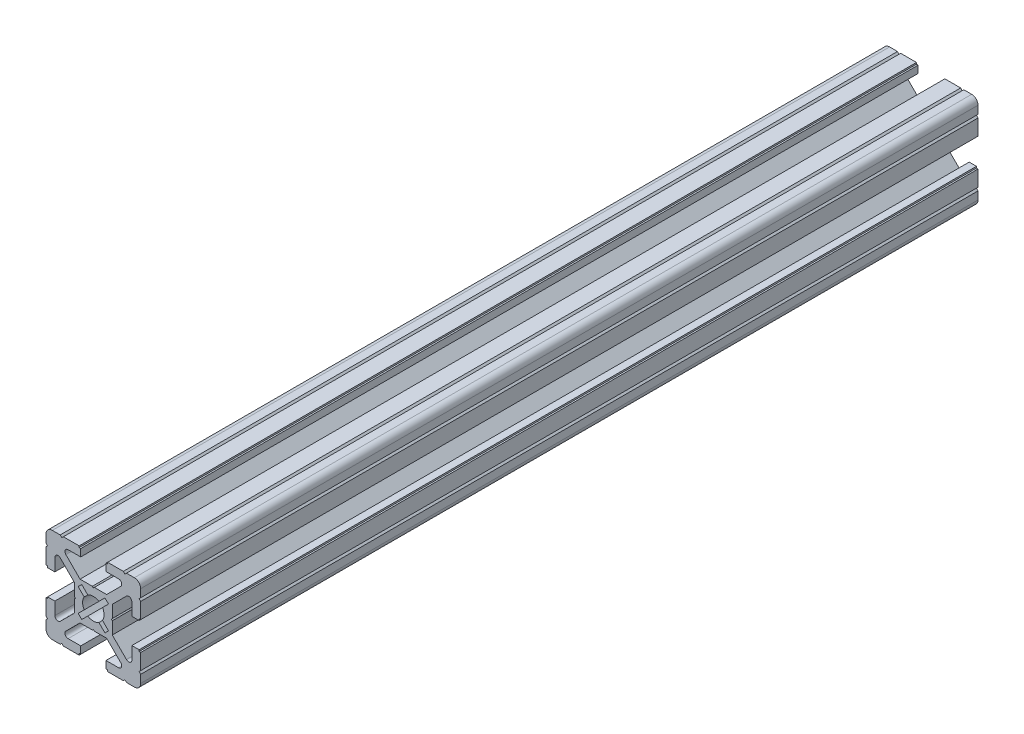
from build123d import *

# Parameters (mm, degrees)
BOSS_EXTRUDE1_DEPTH = 165
BOSS_EXTRUDE2_DEPTH = 100.28


with BuildPart() as part:
    # Sketch1 → Boss-Extrude1 (new body)
    with BuildSketch(Plane(origin=(0, 0, -65), x_dir=(-1, 0, 0), z_dir=(0, 0, -1))):
        with BuildLine():
            Line((-14.999999999, 12.999999999), (-14.999999999, 10.499999999))
            Line((-14.999999999, 10.499999999), (-14.499999999, 9.999999999))
            Line((-14.499999999, 9.999999999), (-14.999999999, 9.5))
            Line((-14.999999999, 9.5), (-14.999999999, 4.5))
            Line((-14.999999999, 4.5), (-14.5, 4.5))
            Line((-14.5, 4.5), (-14.5, 4))
            Line((-14.5, 4), (-12.200000005, 4))
            Line((-12.200000005, 4), (-12.200000005, 7.999999995))
            ThreePointArc((-12.200000005, 7.999999995), (-11.582683434, 8.923879532), (-10.492893215, 8.70710678))
            Line((-10.492893215, 8.70710678), (-6, 4.214213564))
            Line((-6, 4.214213564), (-6, 0.312520903))
            Line((-6, 0.312520903), (-5.7, 0))
            Line((-5.7, 0), (-6, -0.312520901))
            Line((-6, -0.312520901), (-6, -4.214213564))
            Line((-6, -4.214213564), (-10.492893215, -8.70710678))
            ThreePointArc((-10.492893215, -8.70710678), (-11.582683434, -8.923879532), (-12.200000005, -7.999999995))
            Line((-12.200000005, -7.999999995), (-12.200000005, -4))
            Line((-12.200000005, -4), (-14.5, -4))
            Line((-14.5, -4), (-14.5, -4.5))
            Line((-14.5, -4.5), (-14.999999999, -4.5))
            Line((-14.999999999, -4.5), (-14.999999999, -9.500000003))
            Line((-14.999999999, -9.500000003), (-14.499999999, -10.000000002))
            Line((-14.499999999, -10.000000002), (-14.999999999, -10.500000001))
            Line((-14.999999999, -10.500000001), (-14.999999999, -13))
            ThreePointArc((-14.999999999, -13), (-14.414213561, -14.414213562), (-12.999999999, -15))
            Line((-12.999999999, -15), (-10.5, -15))
            Line((-10.5, -15), (-10.000000001, -14.500000001))
            Line((-10.000000001, -14.500000001), (-9.500000001, -15))
            Line((-9.500000001, -15), (-4.5, -15))
            Line((-4.5, -15), (-4.5, -14.5))
            Line((-4.5, -14.5), (-4, -14.5))
            Line((-4, -14.5), (-4, -12.200000005))
            Line((-4, -12.200000005), (-7.999999995, -12.200000005))
            ThreePointArc((-7.999999995, -12.200000005), (-8.923879532, -11.582683434), (-8.70710678, -10.492893215))
            Line((-8.70710678, -10.492893215), (-4.214213564, -6))
            Line((-4.214213564, -6), (-0.312520903, -6))
            Line((-0.312520903, -6), (0, -5.7))
            Line((0, -5.7), (0.312520901, -6))
            Line((0.312520901, -6), (4.214213564, -6))
            Line((4.214213564, -6), (8.70710678, -10.492893215))
            ThreePointArc((8.70710678, -10.492893215), (8.923879532, -11.582683434), (7.999999995, -12.200000005))
            Line((7.999999995, -12.200000005), (4, -12.200000005))
            Line((4, -12.200000005), (4, -14.5))
            Line((4, -14.5), (4.5, -14.5))
            Line((4.5, -14.5), (4.5, -15))
            Line((4.5, -15), (9.500000001, -15))
            Line((9.500000001, -15), (9.989897949, -14.5))
            Line((9.989897949, -14.5), (10.489897949, -15))
            Line((10.489897949, -15), (13, -15))
            ThreePointArc((13, -15), (14.414213562, -14.414213562), (15, -13))
            Line((15, -13), (15, -10.5))
            Line((15, -10.5), (14.500000001, -10.000000001))
            Line((14.500000001, -10.000000001), (15, -9.500000001))
            Line((15, -9.500000001), (15, -4.5))
            Line((15, -4.5), (14.5, -4.5))
            Line((14.5, -4.5), (14.5, -4))
            Line((14.5, -4), (12.200000005, -4))
            Line((12.200000005, -4), (12.200000005, -7.999999995))
            ThreePointArc((12.200000005, -7.999999995), (11.582683434, -8.923879532), (10.492893215, -8.70710678))
            Line((10.492893215, -8.70710678), (6, -4.214213564))
            Line((6, -4.214213564), (6, -0.312520903))
            Line((6, -0.312520903), (5.7, 0))
            Line((5.7, 0), (6, 0.312520901))
            Line((6, 0.312520901), (6, 4.214213564))
            Line((6, 4.214213564), (10.492893215, 8.707106779))
            ThreePointArc((10.492893215, 8.707106779), (11.582683434, 8.923879532), (12.200000005, 7.999999994))
            Line((12.200000005, 7.999999994), (12.200000005, 4))
            Line((12.200000005, 4), (14.5, 4))
            Line((14.5, 4), (14.5, 4.5))
            Line((14.5, 4.5), (15, 4.5))
            Line((15, 4.5), (15, 9.500000001))
            Line((15, 9.500000001), (14.500000001, 10.000000001))
            Line((14.500000001, 10.000000001), (15, 10.5))
            Line((15, 10.5), (15, 12.999999999))
            ThreePointArc((15, 12.999999999), (14.414213562, 14.414213561), (13, 14.999999999))
            Line((13, 14.999999999), (10.500000001, 14.999999999))
            Line((10.500000001, 14.999999999), (10.000000002, 14.499999999))
            Line((10.000000002, 14.499999999), (9.500000003, 14.999999999))
            Line((9.500000003, 14.999999999), (4.5, 14.999999999))
            Line((4.5, 14.999999999), (4.5, 14.5))
            Line((4.5, 14.5), (4, 14.5))
            Line((4, 14.5), (4, 12.200000005))
            Line((4, 12.200000005), (7.999999995, 12.200000005))
            ThreePointArc((7.999999995, 12.200000005), (8.923879532, 11.582683434), (8.70710678, 10.492893215))
            Line((8.70710678, 10.492893215), (4.214213564, 6))
            Line((4.214213564, 6), (0.312520903, 6))
            Line((0.312520903, 6), (0, 5.7))
            Line((0, 5.7), (-0.312520901, 6))
            Line((-0.312520901, 6), (-4.214213564, 6))
            Line((-4.214213564, 6), (-8.707106779, 10.492893215))
            ThreePointArc((-8.707106779, 10.492893215), (-8.923879532, 11.582683434), (-7.999999994, 12.200000005))
            Line((-7.999999994, 12.200000005), (-4, 12.200000005))
            Line((-4, 12.200000005), (-4, 14.5))
            Line((-4, 14.5), (-4.5, 14.5))
            Line((-4.5, 14.5), (-4.5, 14.999999999))
            Line((-4.5, 14.999999999), (-9.5, 14.999999999))
            Line((-9.5, 14.999999999), (-9.999999999, 14.499999999))
            Line((-9.999999999, 14.499999999), (-10.499999999, 14.999999999))
            Line((-10.499999999, 14.999999999), (-12.999999999, 14.999999999))
            ThreePointArc((-12.999999999, 14.999999999), (-14.414213561, 14.414213561), (-14.999999999, 12.999999999))
        make_face()
        with BuildLine():
            Line((4.808326112, 3.676955262), (2.902349714, 1.770978864))
            ThreePointArc((2.902349714, 1.770978864), (3.4, 0), (2.902349714, -1.770978864))
            Line((2.902349714, -1.770978864), (4.808326112, -3.676955262))
            Line((4.808326112, -3.676955262), (3.676955262, -4.808326112))
            Line((3.676955262, -4.808326112), (1.770978864, -2.902349714))
            ThreePointArc((1.770978864, -2.902349714), (0, -3.4), (-1.770978864, -2.902349714))
            Line((-1.770978864, -2.902349714), (-3.676955262, -4.808326112))
            Line((-3.676955262, -4.808326112), (-4.808326112, -3.676955262))
            Line((-4.808326112, -3.676955262), (-2.902349714, -1.770978864))
            ThreePointArc((-2.902349714, -1.770978864), (-3.4, 0), (-2.902349714, 1.770978864))
            Line((-2.902349714, 1.770978864), (-4.808326112, 3.676955262))
            Line((-4.808326112, 3.676955262), (-3.676955262, 4.808326112))
            Line((-3.676955262, 4.808326112), (-1.770978864, 2.902349714))
            ThreePointArc((-1.770978864, 2.902349714), (0, 3.4), (1.770978864, 2.902349714))
            Line((1.770978864, 2.902349714), (3.676955262, 4.808326112))
            Line((3.676955262, 4.808326112), (4.808326112, 3.676955262))
        make_face(mode=Mode.SUBTRACT)
    extrude(amount=-BOSS_EXTRUDE1_DEPTH)

    # Sketch2 → Boss-Extrude2 (add)
    with BuildSketch(Plane.XY.offset(100)):
        with BuildLine():
            Line((12.999999999, 14.999999999), (10.499999999, 14.999999999))
            Line((10.499999999, 14.999999999), (9.999999999, 14.499999999))
            Line((9.999999999, 14.499999999), (9.5, 14.999999999))
            Line((9.5, 14.999999999), (4.5, 14.999999999))
            Line((4.5, 14.999999999), (4.5, 14.5))
            Line((4.5, 14.5), (4, 14.5))
            Line((4, 14.5), (4, 12.200000005))
            Line((4, 12.200000005), (7.999999994, 12.200000005))
            ThreePointArc((7.999999994, 12.200000005), (8.923879532, 11.582683434), (8.707106779, 10.492893215))
            Line((8.707106779, 10.492893215), (4.214213564, 6))
            Line((4.214213564, 6), (0.312520901, 6))
            Line((0.312520901, 6), (0, 5.7))
            Line((0, 5.7), (-0.312520903, 6))
            Line((-0.312520903, 6), (-4.214213564, 6))
            Line((-4.214213564, 6), (-8.70710678, 10.492893215))
            ThreePointArc((-8.70710678, 10.492893215), (-8.923879532, 11.582683434), (-7.999999995, 12.200000005))
            Line((-7.999999995, 12.200000005), (-4, 12.200000005))
            Line((-4, 12.200000005), (-4, 14.5))
            Line((-4, 14.5), (-4.5, 14.5))
            Line((-4.5, 14.5), (-4.5, 14.999999999))
            Line((-4.5, 14.999999999), (-9.500000003, 14.999999999))
            Line((-9.500000003, 14.999999999), (-10.000000002, 14.499999999))
            Line((-10.000000002, 14.499999999), (-10.500000001, 14.999999999))
            Line((-10.500000001, 14.999999999), (-13, 14.999999999))
            ThreePointArc((-13, 14.999999999), (-14.414213562, 14.414213561), (-15, 12.999999999))
            Line((-15, 12.999999999), (-15, 10.5))
            Line((-15, 10.5), (-14.500000001, 10.000000001))
            Line((-14.500000001, 10.000000001), (-15, 9.500000001))
            Line((-15, 9.500000001), (-15, 4.5))
            Line((-15, 4.5), (-14.5, 4.5))
            Line((-14.5, 4.5), (-14.5, 4))
            Line((-14.5, 4), (-12.200000005, 4))
            Line((-12.200000005, 4), (-12.200000005, 7.999999994))
            ThreePointArc((-12.200000005, 7.999999994), (-11.582683434, 8.923879532), (-10.492893215, 8.707106779))
            Line((-10.492893215, 8.707106779), (-6, 4.214213564))
            Line((-6, 4.214213564), (-6, 0.312520901))
            Line((-6, 0.312520901), (-5.7, 0))
            Line((-5.7, 0), (-6, -0.312520903))
            Line((-6, -0.312520903), (-6, -4.214213564))
            Line((-6, -4.214213564), (-10.492893215, -8.70710678))
            ThreePointArc((-10.492893215, -8.70710678), (-11.582683434, -8.923879532), (-12.200000005, -7.999999995))
            Line((-12.200000005, -7.999999995), (-12.200000005, -4))
            Line((-12.200000005, -4), (-14.5, -4))
            Line((-14.5, -4), (-14.5, -4.5))
            Line((-14.5, -4.5), (-15, -4.5))
            Line((-15, -4.5), (-15, -9.500000001))
            Line((-15, -9.500000001), (-14.500000001, -10.000000001))
            Line((-14.500000001, -10.000000001), (-15, -10.5))
            Line((-15, -10.5), (-15, -13))
            ThreePointArc((-15, -13), (-14.414213562, -14.414213562), (-13, -15))
            Line((-13, -15), (-10.489897949, -15))
            Line((-10.489897949, -15), (-9.989897949, -14.5))
            Line((-9.989897949, -14.5), (-9.500000001, -15))
            Line((-9.500000001, -15), (-4.5, -15))
            Line((-4.5, -15), (-4.5, -14.5))
            Line((-4.5, -14.5), (-4, -14.5))
            Line((-4, -14.5), (-4, -12.200000005))
            Line((-4, -12.200000005), (-7.999999995, -12.200000005))
            ThreePointArc((-7.999999995, -12.200000005), (-8.923879532, -11.582683434), (-8.70710678, -10.492893215))
            Line((-8.70710678, -10.492893215), (-4.214213564, -6))
            Line((-4.214213564, -6), (-0.312520901, -6))
            Line((-0.312520901, -6), (0, -5.7))
            Line((0, -5.7), (0.312520903, -6))
            Line((0.312520903, -6), (4.214213564, -6))
            Line((4.214213564, -6), (8.70710678, -10.492893215))
            ThreePointArc((8.70710678, -10.492893215), (8.923879532, -11.582683434), (7.999999995, -12.200000005))
            Line((7.999999995, -12.200000005), (4, -12.200000005))
            Line((4, -12.200000005), (4, -14.5))
            Line((4, -14.5), (4.5, -14.5))
            Line((4.5, -14.5), (4.5, -15))
            Line((4.5, -15), (9.500000001, -15))
            Line((9.500000001, -15), (10.000000001, -14.500000001))
            Line((10.000000001, -14.500000001), (10.5, -15))
            Line((10.5, -15), (12.999999999, -15))
            ThreePointArc((12.999999999, -15), (14.414213561, -14.414213562), (14.999999999, -13))
            Line((14.999999999, -13), (14.999999999, -10.500000001))
            Line((14.999999999, -10.500000001), (14.499999999, -10.000000002))
            Line((14.499999999, -10.000000002), (14.999999999, -9.500000003))
            Line((14.999999999, -9.500000003), (14.999999999, -4.5))
            Line((14.999999999, -4.5), (14.5, -4.5))
            Line((14.5, -4.5), (14.5, -4))
            Line((14.5, -4), (12.200000005, -4))
            Line((12.200000005, -4), (12.200000005, -7.999999995))
            ThreePointArc((12.200000005, -7.999999995), (11.582683434, -8.923879532), (10.492893215, -8.70710678))
            Line((10.492893215, -8.70710678), (6, -4.214213564))
            Line((6, -4.214213564), (6, -0.312520901))
            Line((6, -0.312520901), (5.7, 0))
            Line((5.7, 0), (6, 0.312520903))
            Line((6, 0.312520903), (6, 4.214213564))
            Line((6, 4.214213564), (10.492893215, 8.70710678))
            ThreePointArc((10.492893215, 8.70710678), (11.582683434, 8.923879532), (12.200000005, 7.999999995))
            Line((12.200000005, 7.999999995), (12.200000005, 4))
            Line((12.200000005, 4), (14.5, 4))
            Line((14.5, 4), (14.5, 4.5))
            Line((14.5, 4.5), (14.999999999, 4.5))
            Line((14.999999999, 4.5), (14.999999999, 9.5))
            Line((14.999999999, 9.5), (14.499999999, 9.999999999))
            Line((14.499999999, 9.999999999), (14.999999999, 10.499999999))
            Line((14.999999999, 10.499999999), (14.999999999, 12.999999999))
            ThreePointArc((14.999999999, 12.999999999), (14.414213561, 14.414213561), (12.999999999, 14.999999999))
        make_face()
        with BuildLine():
            Line((-1.770978864, 2.902349714), (-3.676955262, 4.808326112))
            Line((-3.676955262, 4.808326112), (-4.808326112, 3.676955262))
            Line((-4.808326112, 3.676955262), (-2.902349714, 1.770978864))
            ThreePointArc((-2.902349714, 1.770978864), (-3.4, 0), (-2.902349714, -1.770978864))
            Line((-2.902349714, -1.770978864), (-4.808326112, -3.676955262))
            Line((-4.808326112, -3.676955262), (-3.676955262, -4.808326112))
            Line((-3.676955262, -4.808326112), (-1.770978864, -2.902349714))
            ThreePointArc((-1.770978864, -2.902349714), (0, -3.4), (1.770978864, -2.902349714))
            Line((1.770978864, -2.902349714), (3.676955262, -4.808326112))
            Line((3.676955262, -4.808326112), (4.808326112, -3.676955262))
            Line((4.808326112, -3.676955262), (2.902349714, -1.770978864))
            ThreePointArc((2.902349714, -1.770978864), (3.4, 0), (2.902349714, 1.770978864))
            Line((2.902349714, 1.770978864), (4.808326112, 3.676955262))
            Line((4.808326112, 3.676955262), (3.676955262, 4.808326112))
            Line((3.676955262, 4.808326112), (1.770978864, 2.902349714))
            ThreePointArc((1.770978864, 2.902349714), (0, 3.4), (-1.770978864, 2.902349714))
        make_face(mode=Mode.SUBTRACT)
    extrude(amount=BOSS_EXTRUDE2_DEPTH)


solid = part.part
